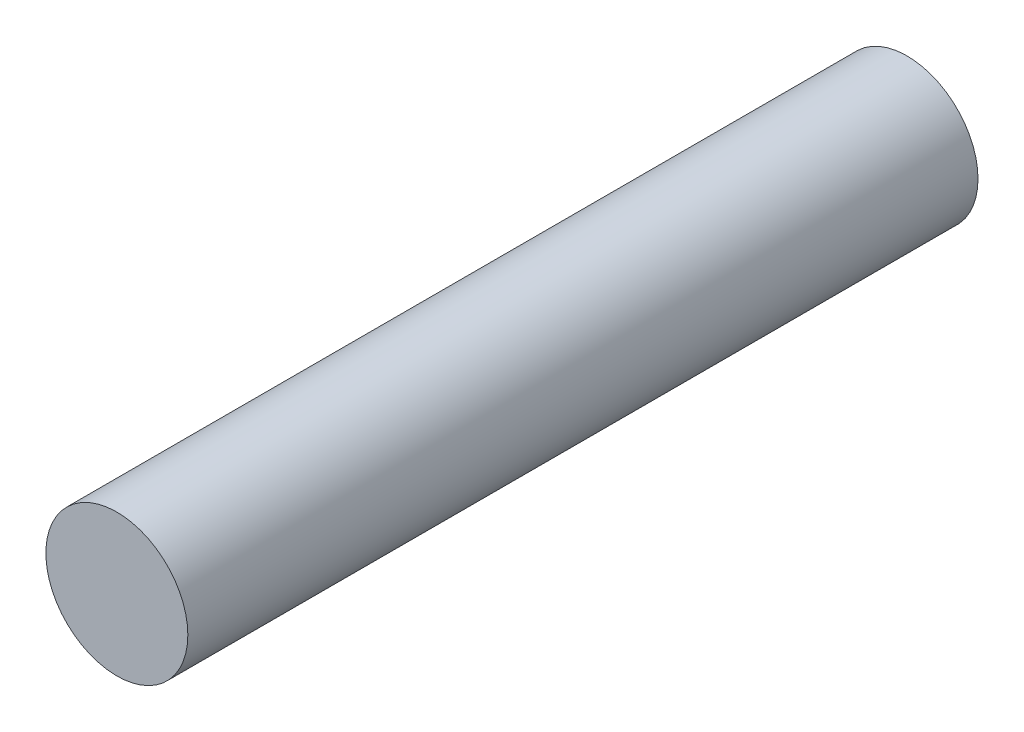
from build123d import *

# Parameters (mm, degrees)
SKETCH1_R           = 18.25625
BOSS_EXTRUDE1_DEPTH = 101.6


with BuildPart() as part:
    # Sketch1 → Boss-Extrude1 (new body, symmetric)
    with BuildSketch(Plane.XY):
        Circle(SKETCH1_R)
    extrude(amount=BOSS_EXTRUDE1_DEPTH, both=True)


solid = part.part
